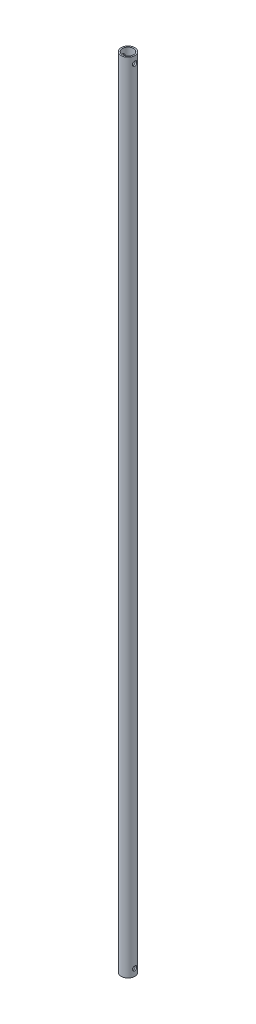
from build123d import *

# Parameters (mm, degrees)
SKETCH1_R            = 5
SKETCH1_R_2          = 4
BOSS_EXTRUDE1_DEPTH  = 289.5
M3_CLEARANCE_HOLE1_D = 3.2


with BuildPart() as part:
    # Sketch1 → Boss-Extrude1 (new, symmetric)
    with BuildSketch(Plane(origin=(0, 0, 0), x_dir=(1, 0, 0), z_dir=(0, 1, 0))):
        Circle(SKETCH1_R)
        Circle(SKETCH1_R_2, mode=Mode.SUBTRACT)
    extrude(amount=BOSS_EXTRUDE1_DEPTH, both=True)

    # M3 Clearance Hole1 (through all)
    with Locations(Plane.ZY.offset(5)):
        with Locations((0, -284.5)):
            m3_clearance_hole1 = Hole(M3_CLEARANCE_HOLE1_D / 2)

    # Mirror1: M3 Clearance Hole1 across plane
    add(m3_clearance_hole1.mirror(Plane.ZX), mode=Mode.SUBTRACT)


solid = part.part
